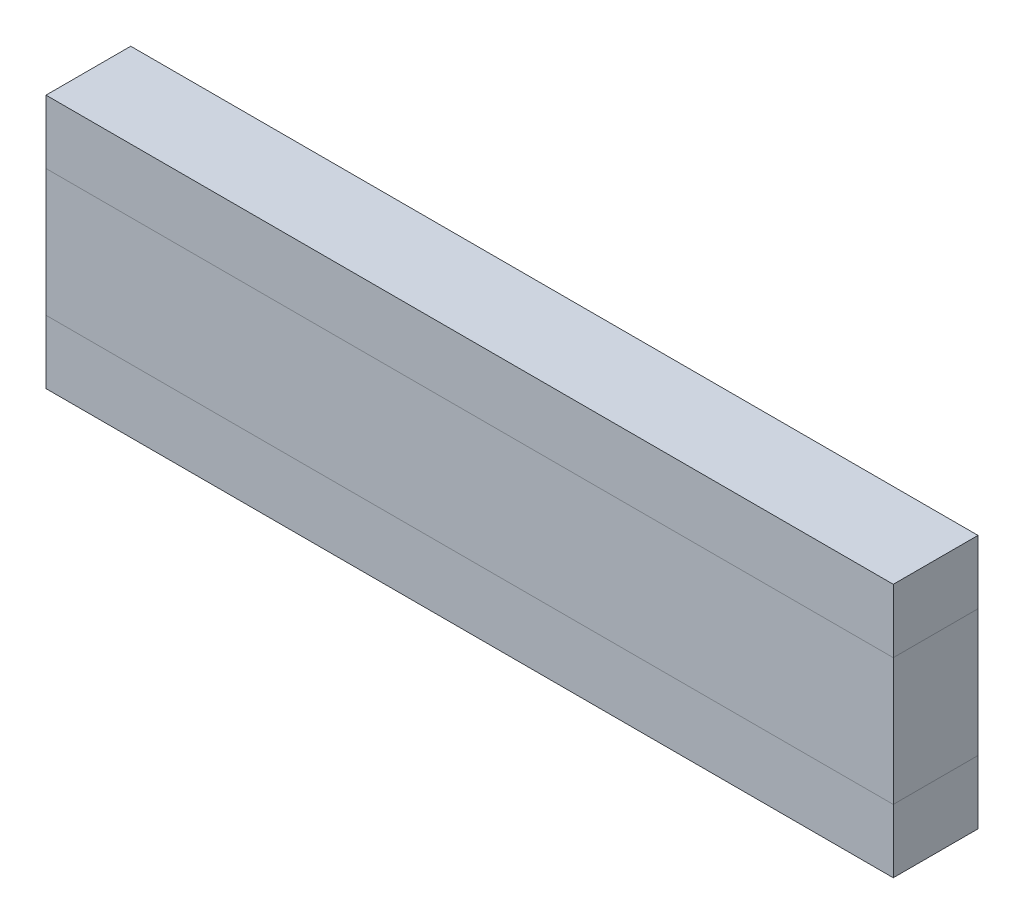
from build123d import *

# Parameters (mm, degrees)
SKIZZE1_W                                   = 100
SKIZZE1_H                                   = 15
AUFSATZ_LINEAR_AUSTRAGEN1_DEPTH             = 5
AUFSATZ_LINEAR_AUSTRAGEN2_REACH             = 7
SKIZZE2_W                                   = 100
SKIZZE2_H                                   = 7.5
AUFSATZ_LINEAR_AUSTRAGEN2_DIRECTION_2_REACH = 7


with BuildPart() as part:
    # Skizze1 → Aufsatz-Linear austragen1 (new body, symmetric)
    with BuildSketch(Plane.XY):
        Rectangle(SKIZZE1_W, SKIZZE1_H)
    extrude(amount=AUFSATZ_LINEAR_AUSTRAGEN1_DEPTH, both=True)


with BuildPart() as body_2:

    # Aufsatz-Linear austragen2: up to this face of the body (flat: up to its plane)
    aufsatz_linear_austragen2_end = Plane(part.part.faces().sort_by_distance((0, 0, 5))[0])
    # Skizze2 → Aufsatz-Linear austragen2 (new body, up to the picked face)
    with BuildSketch(Plane.XY, mode=Mode.PRIVATE) as aufsatz_linear_austragen2_sk1:
        with Locations((0, 11.25)):
            Rectangle(SKIZZE2_W, SKIZZE2_H)
    aufsatz_linear_austragen2_tool1 = split(extrude(aufsatz_linear_austragen2_sk1.sketch, amount=AUFSATZ_LINEAR_AUSTRAGEN2_REACH, mode=Mode.PRIVATE), bisect_by=aufsatz_linear_austragen2_end, keep=Keep.BOTH, mode=Mode.PRIVATE)
    add(aufsatz_linear_austragen2_tool1.solids().sort_by(Axis((0, 11.25, 0), (0, 0, 1)))[0])
    # Skizze2 → Aufsatz-Linear austragen2 (new body, up to the picked face)
    with BuildSketch(Plane.XY, mode=Mode.PRIVATE) as aufsatz_linear_austragen2_sk2:
        with Locations((0, -11.25)):
            Rectangle(SKIZZE2_W, SKIZZE2_H)
    aufsatz_linear_austragen2_tool2 = split(extrude(aufsatz_linear_austragen2_sk2.sketch, amount=AUFSATZ_LINEAR_AUSTRAGEN2_REACH, mode=Mode.PRIVATE), bisect_by=aufsatz_linear_austragen2_end, keep=Keep.BOTH, mode=Mode.PRIVATE)
    add(aufsatz_linear_austragen2_tool2.solids().sort_by(Axis((0, -11.25, 0), (0, 0, 1)))[0])


    # Aufsatz-Linear austragen2 direction 2: up to this face of the body (flat: up to its plane)
    aufsatz_linear_austragen2_direction_2_end = Plane(part.part.faces().sort_by_distance((0, 0, -5))[0])
    # Skizze2 → Aufsatz-Linear austragen2 direction 2 (add, up to the picked face)
    with BuildSketch(Plane.XY, mode=Mode.PRIVATE) as aufsatz_linear_austragen2_direction_2_sk1:
        with Locations((0, 11.25)):
            Rectangle(SKIZZE2_W, SKIZZE2_H)
    aufsatz_linear_austragen2_direction_2_tool1 = split(extrude(aufsatz_linear_austragen2_direction_2_sk1.sketch, amount=-AUFSATZ_LINEAR_AUSTRAGEN2_DIRECTION_2_REACH, mode=Mode.PRIVATE), bisect_by=aufsatz_linear_austragen2_direction_2_end, keep=Keep.BOTH, mode=Mode.PRIVATE)
    add(aufsatz_linear_austragen2_direction_2_tool1.solids().sort_by(Axis((0, 11.25, 0), (0, 0, -1)))[0])
    # Skizze2 → Aufsatz-Linear austragen2 direction 2 (add, up to the picked face)
    with BuildSketch(Plane.XY, mode=Mode.PRIVATE) as aufsatz_linear_austragen2_direction_2_sk2:
        with Locations((0, -11.25)):
            Rectangle(SKIZZE2_W, SKIZZE2_H)
    aufsatz_linear_austragen2_direction_2_tool2 = split(extrude(aufsatz_linear_austragen2_direction_2_sk2.sketch, amount=-AUFSATZ_LINEAR_AUSTRAGEN2_DIRECTION_2_REACH, mode=Mode.PRIVATE), bisect_by=aufsatz_linear_austragen2_direction_2_end, keep=Keep.BOTH, mode=Mode.PRIVATE)
    add(aufsatz_linear_austragen2_direction_2_tool2.solids().sort_by(Axis((0, -11.25, 0), (0, 0, -1)))[0])


solid = Compound([part.part, body_2.part])
